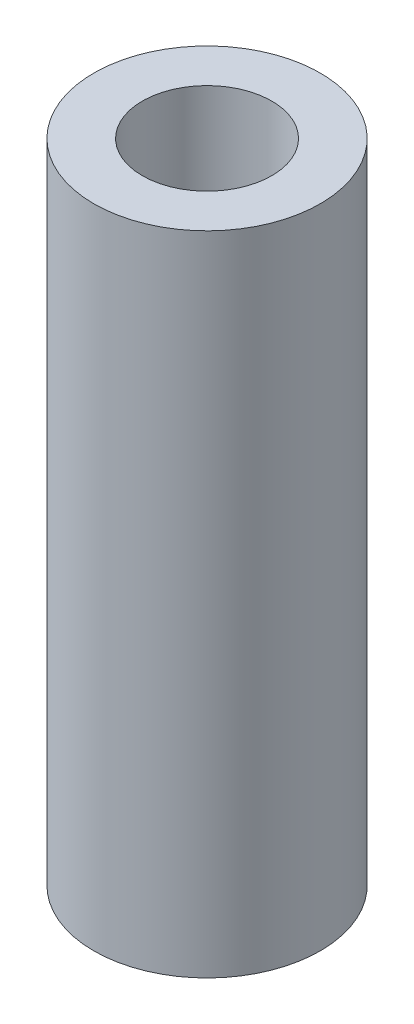
from build123d import *

# Parameters (mm, degrees)
SKETCH1_R           = 70
SKETCH1_R_2         = 40
BOSS_EXTRUDE1_DEPTH = 400


with BuildPart() as part:
    # Sketch1 → Boss-Extrude1 (new body)
    with BuildSketch(Plane(origin=(0, 0, 0), x_dir=(1, 0, 0), z_dir=(0, 1, 0))):
        Circle(SKETCH1_R)
        Circle(SKETCH1_R_2, mode=Mode.SUBTRACT)
    extrude(amount=BOSS_EXTRUDE1_DEPTH)


solid = part.part
